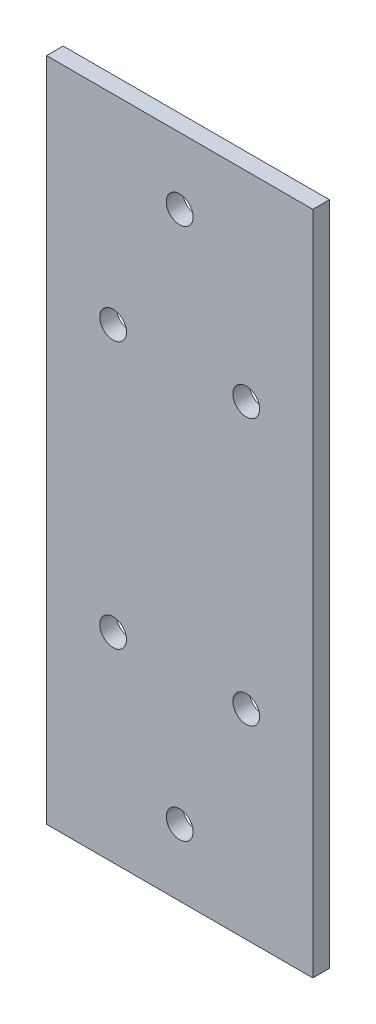
from build123d import *

# Parameters (mm, degrees)
SKETCH1_W           = 50.8
SKETCH1_H           = 127
SKETCH1_R           = 2.5527
BOSS_EXTRUDE1_DEPTH = 3.175


with BuildPart() as part:
    # Sketch1 → Boss-Extrude1 (new body)
    with BuildSketch(Plane.XY):
        with Locations((-17.248016786, -51.329317728)):
            Rectangle(SKETCH1_W, SKETCH1_H)
        with Locations((-17.248016786, -0.529317728)):
            Circle(SKETCH1_R, mode=Mode.SUBTRACT)
        with Locations((-29.948016786, -25.929317728)):
            Circle(SKETCH1_R, mode=Mode.SUBTRACT)
        with Locations((-4.548016786, -25.929317728)):
            Circle(SKETCH1_R, mode=Mode.SUBTRACT)
        with Locations((-17.248016786, -102.129317728)):
            Circle(SKETCH1_R, mode=Mode.SUBTRACT)
        with Locations((-4.548016786, -76.729317728)):
            Circle(SKETCH1_R, mode=Mode.SUBTRACT)
        with Locations((-29.948016786, -76.729317728)):
            Circle(SKETCH1_R, mode=Mode.SUBTRACT)
    extrude(amount=BOSS_EXTRUDE1_DEPTH)


solid = part.part
